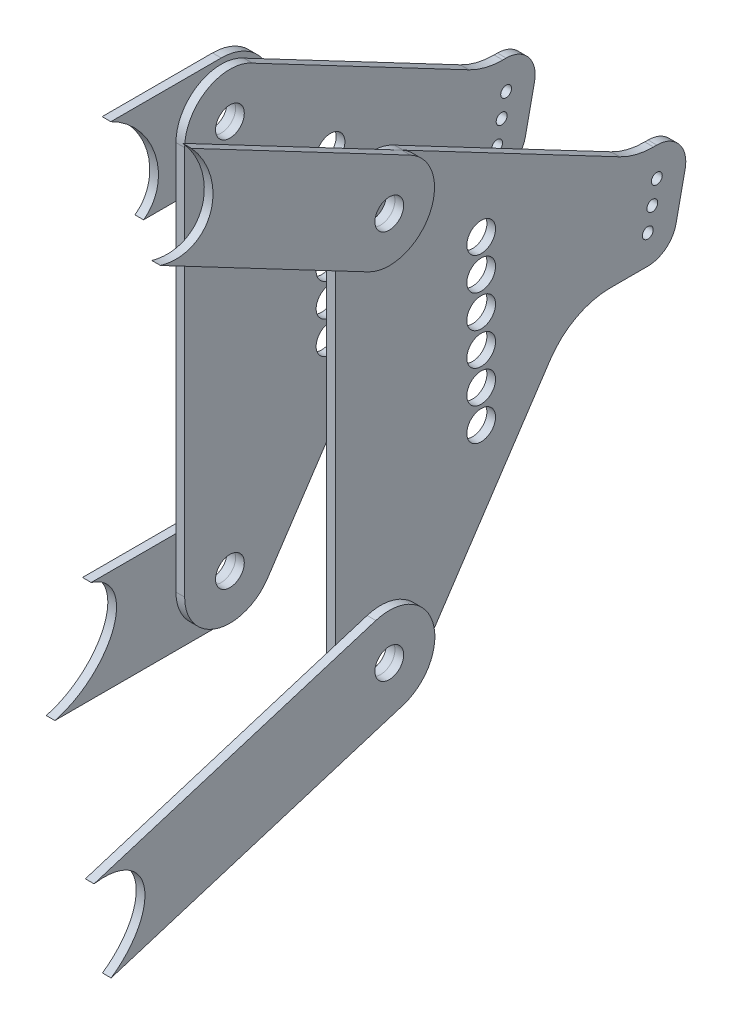
from build123d import *

# Parameters (mm, degrees)
SKETCH1_ON_SEGMENT_1_R          = 12.7
SKETCH1_ON_SEGMENT_1_R_2        = 11.7
STRUCTURAL_MEMBER1_DEPTH        = 319.110282105
SKETCH1_R                       = 12.7
SKETCH1_R_2                     = 11.7
STRUCTURAL_MEMBER1_2_DEPTH      = 348.268544896
STRUCTURAL_MEMBER1_2_DEPTH_BACK = 35.176416566
SKETCH13_R                      = 3.96875
BOSS_EXTRUDE2_DEPTH             = 2.4
BOSS_EXTRUDE2_2_DEPTH           = 2.4
SKETCH12_R                      = 3.96875
BOSS_EXTRUDE6_DEPTH             = 2.4
BOSS_EXTRUDE6_2_DEPTH           = 2.4
SKETCH15_R                      = 1.5
SKETCH15_R_2                    = 3.96875
BOSS_EXTRUDE5_DEPTH             = 2.4
BOSS_EXTRUDE9_START             = 44
SKETCH15_4_R                    = 1.5
SKETCH15_4_R_2                  = 3.96875
BOSS_EXTRUDE9_DEPTH             = 2.4


with BuildPart() as part:
    # Sketch1 on segment 1 (carried to segment 1) → Structural Member1 (new body)
    with BuildSketch(Plane(origin=(200, -114, 166.2), x_dir=(0.662842595, 0.077067996, -0.744781994), z_dir=(-0.704389382, 0.401501948, -0.585347576))):
        Circle(SKETCH1_ON_SEGMENT_1_R)
        Circle(SKETCH1_ON_SEGMENT_1_R_2, mode=Mode.SUBTRACT)
    extrude(amount=STRUCTURAL_MEMBER1_DEPTH)

    # Structural Member1 mitre 1
    split(bisect_by=Plane(origin=(0, 0, 0), x_dir=(0.999997347, -0.002303489, 0), z_dir=(-0.00228788, -0.993220961, 0.116219136)), keep=Keep.TOP)


with BuildPart() as body_2:
    # Sketch1 → Structural Member1 2 (new, two sides)
    with BuildSketch(Plane(origin=(0, 0, 0), x_dir=(0.6620893332856919, -0.2499400195970222, -0.7065180120514609), z_dir=(0.706518012051461, 0.5225852367871229, 0.4772179470001087))) as structural_member1_2_sk:
        Circle(SKETCH1_R)
        Circle(SKETCH1_R_2, mode=Mode.SUBTRACT)
    extrude(amount=STRUCTURAL_MEMBER1_2_DEPTH)
    extrude(structural_member1_2_sk.sketch, amount=-STRUCTURAL_MEMBER1_2_DEPTH_BACK)

    # Structural Member1 2 mitre 1
    split(bisect_by=Plane(origin=(0, 0, 0), x_dir=(-0.999997347, 0.002303489, 0), z_dir=(0.00228788, 0.993220961, -0.116219136)), keep=Keep.TOP)


with BuildPart() as body_3:
    # Sketch13 → Boss-Extrude2 (new body)
    with BuildSketch(Plane(origin=(82.063, 0, 0), x_dir=(0, 0, -1), z_dir=(1, 0, 0))):
        with BuildLine():
            Line((-53.256842147, 74.698965285), (-22.7704, 74.698965285))
            ThreePointArc((-22.7704, 74.698965285), (-8.7704, 60.698965285), (-22.7704, 46.698965285))
            Line((-22.7704, 46.698965285), (-44.214796592, 46.698965285))
            add(Edge.make_bspline(
                [(-44.214796592, 46.698965285), (-24.227845102, 60.698965285), (-53.256842147, 74.698965285)],
                knots=[6.191776299, 6.191776299, 6.191776299, 8.370224121, 8.370224121, 8.370224121], degree=2, weights=[1, 0.463173329, 1]))
        make_face()
        with Locations((-22.7704, 60.698965285)):
            Circle(SKETCH13_R, mode=Mode.SUBTRACT)
    extrude(amount=BOSS_EXTRUDE2_DEPTH)


with BuildPart() as body_4:
    # Sketch13 → Boss-Extrude2 2 (new body)
    with BuildSketch(Plane(origin=(82.063, 0, 0), x_dir=(0, 0, -1), z_dir=(1, 0, 0))):
        with BuildLine():
            Line((-22.7704, -60.77591), (-68.692351102, -60.77591))
            add(Edge.make_bspline(
                [(-68.692351102, -60.77591), (-13.757574346, -46.77591), (-58.681965412, -32.77591)],
                knots=[1.090552173, 1.090552173, 1.090552173, 3.648403139, 3.648403139, 3.648403139], degree=2, weights=[1, 0.287744448, 1]))
            Line((-58.681965412, -32.77591), (-22.7704, -32.77591))
            ThreePointArc((-22.7704, -32.77591), (-8.7704, -46.77591), (-22.7704, -60.77591))
        make_face()
        with Locations((-22.7704, -46.77591)):
            Circle(SKETCH13_R, mode=Mode.SUBTRACT)
    extrude(amount=BOSS_EXTRUDE2_2_DEPTH)


with BuildPart() as body_5:
    # Sketch12 → Boss-Extrude6 (new body)
    with BuildSketch(Plane(origin=(128.463, 0, 0), x_dir=(0, 0, -1), z_dir=(1, 0, 0))):
        with BuildLine():
            Line((-77.392301625, 103.583282752), (-16.950316747, 71.749358664))
            ThreePointArc((-16.950316747, 71.749358664), (-11.72000662, 54.878882031), (-28.590483253, 49.648571905))
            Line((-28.590483253, 49.648571905), (-85.968627694, 79.868815302))
            add(Edge.make_bspline(
                [(-85.968627694, 79.868815302), (-44.735632447, 67.82206861), (-77.392301625, 103.583282752)],
                knots=[5.423215777, 5.423215777, 5.423215777, 7.853981634, 7.853981634, 7.853981634], degree=2, weights=[1, 0.347977957, 1]))
        make_face()
        with Locations((-22.7704, 60.698965285)):
            Circle(SKETCH12_R, mode=Mode.SUBTRACT)
    extrude(amount=BOSS_EXTRUDE6_DEPTH)


with BuildPart() as body_6:
    # Sketch12 → Boss-Extrude6 2 (new body)
    with BuildSketch(Plane(origin=(128.463, 0, 0), x_dir=(0, 0, -1), z_dir=(1, 0, 0))):
        with BuildLine():
            Line((-19.05338055, -58.793410054), (-99.569073428, -83.696958639))
            add(Edge.make_bspline(
                [(-99.569073428, -83.696958639), (-51.5053381, -50.729053541), (-104.286190741, -58.821613174)],
                knots=[1.570796327, 1.570796327, 1.570796327, 4.112373399, 4.112373399, 4.112373399], degree=2, weights=[1, 0.29552765, 1]))
            Line((-104.286190741, -58.821613174), (-26.48741945, -34.758409946))
            ThreePointArc((-26.48741945, -34.758409946), (-10.752899946, -43.05889055), (-19.05338055, -58.793410054))
        make_face()
        with Locations((-22.7704, -46.77591)):
            Circle(SKETCH12_R, mode=Mode.SUBTRACT)
    extrude(amount=BOSS_EXTRUDE6_2_DEPTH)


with BuildPart() as body_7:
    # Sketch15 → Boss-Extrude5 (new body)
    with BuildSketch(Plane(origin=(84.463, 0, 0), x_dir=(0, 0, -1), z_dir=(1, 0, 0))):
        with BuildLine():
            Line((-35.2704, 60.698965285), (-35.2704, -46.77591))
            ThreePointArc((-35.2704, -46.77591), (-26.38474309, -58.741967163), (-12.360556156, -53.695819764))
            Line((-12.360556156, -53.695819764), (24.046077536, 1.071855622))
            ThreePointArc((24.046077536, 1.071855622), (31.252941839, 7.627210676), (40.701827687, 10))
            Line((40.701827687, 10), (51, 10))
            ThreePointArc((51, 10), (56.034563128, 11.782832308), (58.825180806, 16.336706473))
            Line((58.825180806, 16.336706473), (61.320121096, 28.074477682))
            ThreePointArc((61.320121096, 28.074477682), (59.712107981, 34.772334337), (53.49494029, 37.737771209))
            Line((53.49494029, 37.737771209), (52.571216833, 37.737771209))
            ThreePointArc((52.571216833, 37.737771209), (47.77086942, 38.322399342), (43.251163822, 40.042104737))
            Line((43.251163822, 40.042104737), (-16.494471191, 71.509271367))
            ThreePointArc((-16.494471191, 71.509271367), (-29.007422122, 71.531765248), (-35.2704, 60.698965285))
        make_face()
        with Locations((52.247470145, 23.868885604)):
            Circle(SKETCH15_R, mode=Mode.SUBTRACT)
        with Locations((53.49494029, 29.737771209)):
            Circle(SKETCH15_R, mode=Mode.SUBTRACT)
        with Locations((5, -5)):
            Circle(SKETCH15_R_2, mode=Mode.SUBTRACT)
        with Locations((51, 18)):
            Circle(SKETCH15_R, mode=Mode.SUBTRACT)
        with Locations((5, 4)):
            Circle(SKETCH15_R_2, mode=Mode.SUBTRACT)
        with Locations((5, 13)):
            Circle(SKETCH15_R_2, mode=Mode.SUBTRACT)
        with Locations((-22.7704, -46.77591)):
            Circle(SKETCH15_R_2, mode=Mode.SUBTRACT)
        with Locations((-22.7704, 60.698965285)):
            Circle(SKETCH15_R_2, mode=Mode.SUBTRACT)
        with Locations((5, 22)):
            Circle(SKETCH15_R_2, mode=Mode.SUBTRACT)
        with Locations((5, 31)):
            Circle(SKETCH15_R_2, mode=Mode.SUBTRACT)
        with Locations((5, 40)):
            Circle(SKETCH15_R_2, mode=Mode.SUBTRACT)
    extrude(amount=BOSS_EXTRUDE5_DEPTH)


with BuildPart() as body_8:
    # Sketch15_4 → Boss-Extrude9 (new body)
    with BuildSketch(Plane(origin=(84.463, 0, 0), x_dir=(0, 0, -1), z_dir=(1, 0, 0)).offset(BOSS_EXTRUDE9_START)):
        with BuildLine():
            Line((-35.2704, 60.698965285), (-35.2704, -46.77591))
            ThreePointArc((-35.2704, -46.77591), (-26.38474309, -58.741967163), (-12.360556156, -53.695819764))
            Line((-12.360556156, -53.695819764), (24.046077536, 1.071855622))
            ThreePointArc((24.046077536, 1.071855622), (31.252941839, 7.627210676), (40.701827687, 10))
            Line((40.701827687, 10), (51, 10))
            ThreePointArc((51, 10), (56.034563128, 11.782832308), (58.825180806, 16.336706473))
            Line((58.825180806, 16.336706473), (61.320121096, 28.074477682))
            ThreePointArc((61.320121096, 28.074477682), (59.712107981, 34.772334337), (53.49494029, 37.737771209))
            Line((53.49494029, 37.737771209), (52.571216833, 37.737771209))
            ThreePointArc((52.571216833, 37.737771209), (47.77086942, 38.322399342), (43.251163822, 40.042104737))
            Line((43.251163822, 40.042104737), (-16.494471191, 71.509271367))
            ThreePointArc((-16.494471191, 71.509271367), (-29.007422122, 71.531765248), (-35.2704, 60.698965285))
        make_face()
        with Locations((52.247470145, 23.868885604)):
            Circle(SKETCH15_4_R, mode=Mode.SUBTRACT)
        with Locations((53.49494029, 29.737771209)):
            Circle(SKETCH15_4_R, mode=Mode.SUBTRACT)
        with Locations((5, -5)):
            Circle(SKETCH15_4_R_2, mode=Mode.SUBTRACT)
        with Locations((51, 18)):
            Circle(SKETCH15_4_R, mode=Mode.SUBTRACT)
        with Locations((5, 4)):
            Circle(SKETCH15_4_R_2, mode=Mode.SUBTRACT)
        with Locations((5, 13)):
            Circle(SKETCH15_4_R_2, mode=Mode.SUBTRACT)
        with Locations((-22.7704, -46.77591)):
            Circle(SKETCH15_4_R_2, mode=Mode.SUBTRACT)
        with Locations((-22.7704, 60.698965285)):
            Circle(SKETCH15_4_R_2, mode=Mode.SUBTRACT)
        with Locations((5, 22)):
            Circle(SKETCH15_4_R_2, mode=Mode.SUBTRACT)
        with Locations((5, 31)):
            Circle(SKETCH15_4_R_2, mode=Mode.SUBTRACT)
        with Locations((5, 40)):
            Circle(SKETCH15_4_R_2, mode=Mode.SUBTRACT)
    extrude(amount=-BOSS_EXTRUDE9_DEPTH)


solid = Compound([body_3.part, body_4.part, body_5.part, body_6.part, body_7.part, body_8.part])
